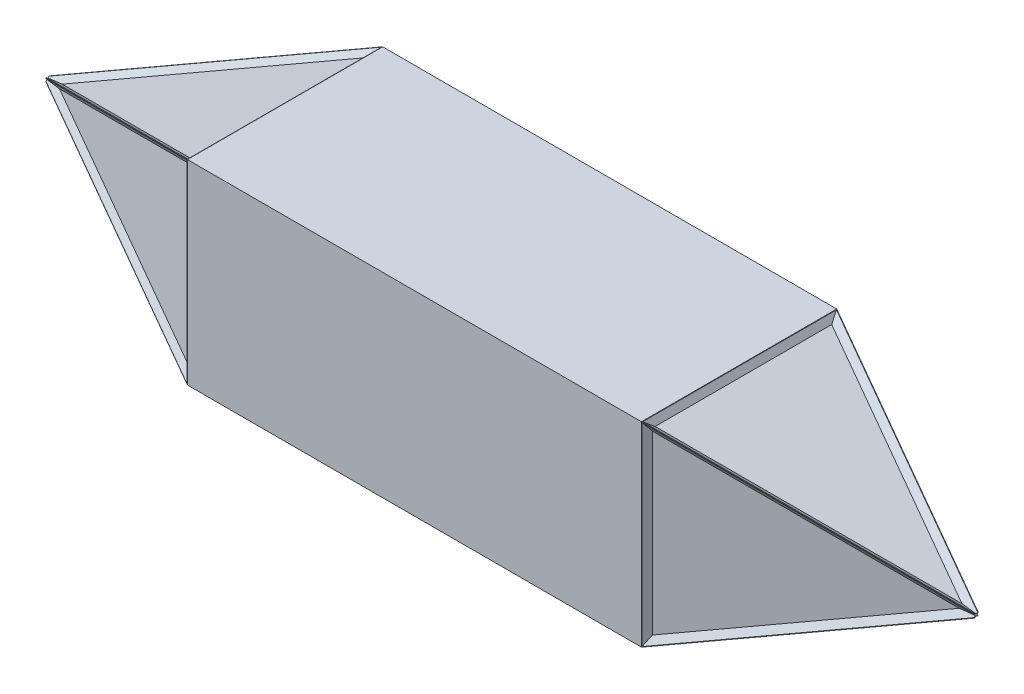
from build123d import *

# Parameters (mm, degrees)
ESQUISSE3_W              = 1000
ESQUISSE3_H              = 430
BOSS_EXTRU_2_DEPTH       = 430
ESQUISSE4_W              = 430
ESQUISSE4_H              = 430
BOSS_EXTRU_3_DEPTH       = 522.4
BOSS_EXTRU_3_TAPER       = 22
ESQUISSE5_W              = 430
ESQUISSE5_H              = 430
BOSS_EXTRU_4_DEPTH       = 522
BOSS_EXTRU_4_TAPER       = 22
ENL_V_MAT_EXTRU_1_DEPTH  = 10
ENL_V_MAT_EXTRU_1_TAPER  = 53
ENL_V_MAT_EXTRU_2_DEPTH  = 10
ENL_V_MAT_EXTRU_2_TAPER  = 53
ENL_V_MAT_EXTRU_3_DEPTH  = 10
ENL_V_MAT_EXTRU_3_TAPER  = 53
ENL_V_MAT_EXTRU_4_DEPTH  = 10
ENL_V_MAT_EXTRU_4_TAPER  = 53
ENL_V_MAT_EXTRU_7_DEPTH  = 10
ENL_V_MAT_EXTRU_7_TAPER  = 53
ENL_V_MAT_EXTRU_8_DEPTH  = 10
ENL_V_MAT_EXTRU_8_TAPER  = 53
ENL_V_MAT_EXTRU_9_DEPTH  = 10
ENL_V_MAT_EXTRU_9_TAPER  = 53
ENL_V_MAT_EXTRU_10_DEPTH = 10
ENL_V_MAT_EXTRU_10_TAPER = 53


with BuildPart() as part:
    # Esquisse3 → Boss.-Extru.2 (new body)
    with BuildSketch(Plane.XY):
        with Locations((500, 215)):
            Rectangle(ESQUISSE3_W, ESQUISSE3_H)
    extrude(amount=BOSS_EXTRU_2_DEPTH)

    # Esquisse4 → Boss.-Extru.3 (add)
    with BuildSketch(Plane.ZY):
        with Locations((215, 215)):
            Rectangle(ESQUISSE4_W, ESQUISSE4_H)
    extrude(amount=BOSS_EXTRU_3_DEPTH, taper=BOSS_EXTRU_3_TAPER)

    # Esquisse5 → Boss.-Extru.4 (add)
    with BuildSketch(Plane(origin=(1000, 0, 0), x_dir=(0, 0, -1), z_dir=(1, 0, 0))):
        with Locations((-215, 215)):
            Rectangle(ESQUISSE5_W, ESQUISSE5_H)
    extrude(amount=BOSS_EXTRU_4_DEPTH, taper=BOSS_EXTRU_4_TAPER)

    # Esquisse6 → Enlèv. mat.-Extru.1 (cut)
    with BuildSketch(Plane(origin=(-149.351549649, 0, 369.658057073), x_dir=(0.927183855, 0, 0.374606593), z_dir=(-0.374606593, 0, 0.927183855))):
        Polygon((160.080835169, 428.557531009), (-410.003981176, 215), (160.080835169, 1.442468991), align=None)
    extrude(amount=-ENL_V_MAT_EXTRU_1_DEPTH, taper=ENL_V_MAT_EXTRU_1_TAPER, mode=Mode.SUBTRACT)

    # Esquisse7 → Enlèv. mat.-Extru.2 (cut)
    with BuildSketch(Plane(origin=(-149.351549649, 369.658057073, 0), x_dir=(0.927183855, 0.374606593, 0), z_dir=(-0.374606593, 0.927183855, 0))):
        Polygon((160.080835169, -428.557531009), (160.080835169, -1.442468991), (-410.003981176, -215), align=None)
    extrude(amount=-ENL_V_MAT_EXTRU_2_DEPTH, taper=ENL_V_MAT_EXTRU_2_TAPER, mode=Mode.SUBTRACT)

    # Esquisse8 → Enlèv. mat.-Extru.3 (cut)
    with BuildSketch(Plane(origin=(0, 0, 0), x_dir=(-0.927183855, 0, 0.374606593), z_dir=(-0.374606593, 0, -0.927183855))):
        Polygon((1, 428.557531009), (1, 1.442468991), (571.084816345, 215), align=None)
    extrude(amount=-ENL_V_MAT_EXTRU_3_DEPTH, taper=ENL_V_MAT_EXTRU_3_TAPER, mode=Mode.SUBTRACT)

    # Esquisse9 → Enlèv. mat.-Extru.4 (cut)
    with BuildSketch(Plane(origin=(0, 0, 0), x_dir=(0.927183855, -0.374606593, 0), z_dir=(-0.374606593, -0.927183855, 0))):
        Polygon((-571.084816345, 215), (-1, 1.442468991), (-1, 428.557531009), align=None)
    extrude(amount=-ENL_V_MAT_EXTRU_4_DEPTH, taper=ENL_V_MAT_EXTRU_4_TAPER, mode=Mode.SUBTRACT)

    # Esquisse12 → Enlèv. mat.-Extru.7 (cut)
    with BuildSketch(Plane(origin=(140.330099831, -347.329185229, 0), x_dir=(-0.927183855, -0.374606593, 0), z_dir=(0.374606593, -0.927183855, 0))):
        Polygon((-928.183854567, -428.557531009), (-928.183854567, -1.442468991), (-1498.268670912, -215), align=None)
    extrude(amount=-ENL_V_MAT_EXTRU_7_DEPTH, taper=ENL_V_MAT_EXTRU_7_TAPER, mode=Mode.SUBTRACT)

    # Esquisse13 → Enlèv. mat.-Extru.8 (cut)
    with BuildSketch(Plane(origin=(289.681649479, 0, 716.987242302), x_dir=(0.927183855, 0, -0.374606593), z_dir=(0.374606593, 0, 0.927183855))):
        Polygon((767.103019398, 428.557531009), (767.103019398, 1.442468991), (1337.187835743, 215), align=None)
    extrude(amount=-ENL_V_MAT_EXTRU_8_DEPTH, taper=ENL_V_MAT_EXTRU_8_TAPER, mode=Mode.SUBTRACT)

    # Esquisse14 → Enlèv. mat.-Extru.9 (cut)
    with BuildSketch(Plane(origin=(289.681649479, 716.987242302, 0), x_dir=(0.927183855, -0.374606593, 0), z_dir=(0.374606593, 0.927183855, 0))):
        Polygon((767.103019398, -1.442468991), (767.103019398, -428.557531009), (1337.187835743, -215), align=None)
    extrude(amount=-ENL_V_MAT_EXTRU_9_DEPTH, taper=ENL_V_MAT_EXTRU_9_TAPER, mode=Mode.SUBTRACT)

    # Esquisse15 → Enlèv. mat.-Extru.10 (cut)
    with BuildSketch(Plane(origin=(140.330099831, 0, -347.329185229), x_dir=(-0.927183855, 0, -0.374606593), z_dir=(0.374606593, 0, -0.927183855))):
        Polygon((-928.183854567, 428.557531009), (-1498.268670912, 215), (-928.183854567, 1.442468991), align=None)
    extrude(amount=-ENL_V_MAT_EXTRU_10_DEPTH, taper=ENL_V_MAT_EXTRU_10_TAPER, mode=Mode.SUBTRACT)


solid = part.part
